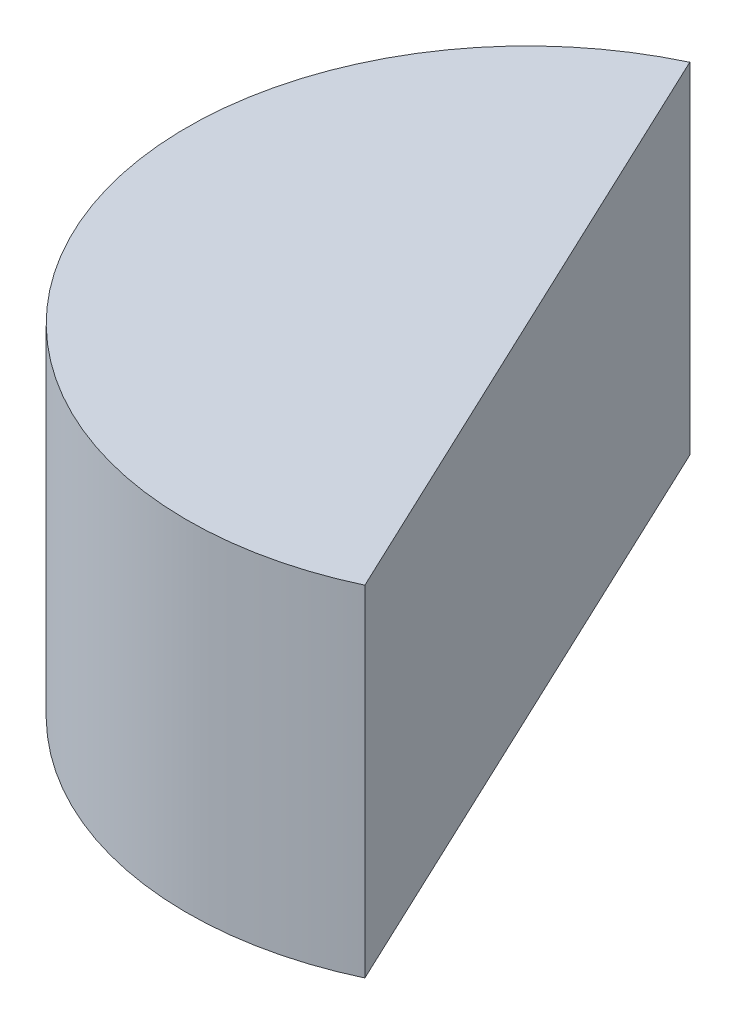
from build123d import *

# Parameters (mm, degrees)
BOSS_EXTRUDE1_DEPTH = 38.1


with BuildPart() as part:
    # Sketch1 → Boss-Extrude1 (new body)
    with BuildSketch(Plane(origin=(0, 0, 0), x_dir=(1, 0, 0), z_dir=(0, 1, 0))):
        with BuildLine():
            Line((16.262082665, -34.455110904), (-16.262082665, 34.455110904))
            ThreePointArc((-16.262082665, 34.455110904), (-34.455110904, -16.262082665), (16.262082665, -34.455110904))
        make_face()
    extrude(amount=BOSS_EXTRUDE1_DEPTH)


solid = part.part
